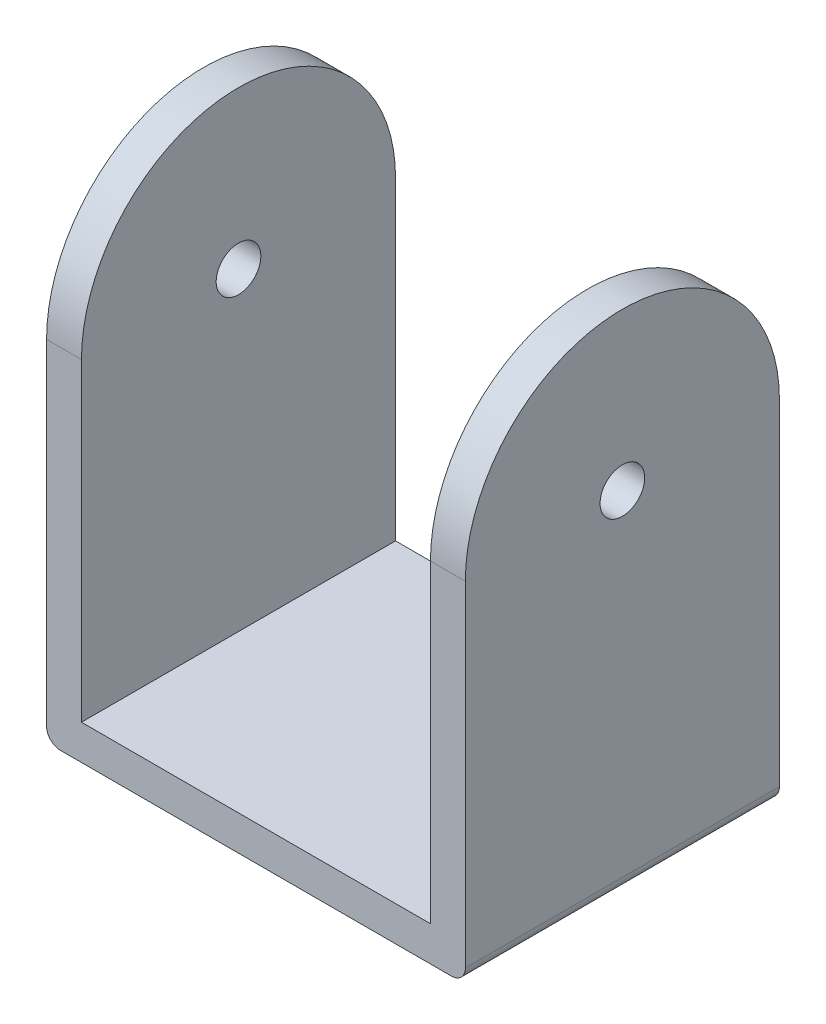
from build123d import *

# Parameters (mm, degrees)
BOSS_EXTRUDE1_DEPTH = 2.5
SKETCH2_W           = 27.5
SKETCH2_H           = 22.5
BOSS_EXTRUDE2_DEPTH = 2.5
SKETCH5_W           = 22.5
SKETCH5_H           = 25
BOSS_EXTRUDE3_DEPTH = 2.5
SKETCH6_R           = 1.6
CUT_EXTRUDE1_DEPTH  = 30
FILLET1_R           = 1


with BuildPart() as part:
    # Sketch1 → Boss-Extrude1 (new body)
    with BuildSketch(Plane(origin=(0, 0, 0), x_dir=(0, 0, -1), z_dir=(1, 0, 0))):
        with BuildLine():
            Line((-11.25, 0), (-11.25, -22.5))
            Line((-11.25, -22.5), (11.25, -22.5))
            Line((11.25, -22.5), (11.25, 0))
            ThreePointArc((11.25, 0), (0, 11.25), (-11.25, 0))
        make_face()
    extrude(amount=BOSS_EXTRUDE1_DEPTH)

    # Sketch2 → Boss-Extrude2 (add)
    with BuildSketch(Plane(origin=(0, -22.5, 0), x_dir=(-1, 0, 0), z_dir=(0, -1, 0))):
        with Locations((-13.75, 0)):
            Rectangle(SKETCH2_W, SKETCH2_H)
    extrude(amount=BOSS_EXTRUDE2_DEPTH)

    # Sketch5 → Boss-Extrude3 (add)
    with BuildSketch(Plane(origin=(27.5, 0, 0), x_dir=(0, 0, -1), z_dir=(1, 0, 0))):
        with BuildLine():
            ThreePointArc((-11.25, 0), (0, 11.25), (11.25, 0))
            Line((11.25, 0), (-11.25, 0))
        make_face()
        with Locations((0, -12.5)):
            Rectangle(SKETCH5_W, SKETCH5_H)
    extrude(amount=BOSS_EXTRUDE3_DEPTH)

    # Sketch6 → Cut-Extrude1 (cut)
    with BuildSketch(Plane(origin=(30, 0, 0), x_dir=(0, 0, -1), z_dir=(1, 0, 0))):
        Circle(SKETCH6_R)
    extrude(amount=-CUT_EXTRUDE1_DEPTH, mode=Mode.SUBTRACT)

    # Fillet1
    fillet1_edges = [part.edges().sort_by_distance(p)[0] for p in [
        (0, -25, 0),
        (30, -25, 0),
    ]]
    fillet(fillet1_edges, radius=FILLET1_R)


solid = part.part
